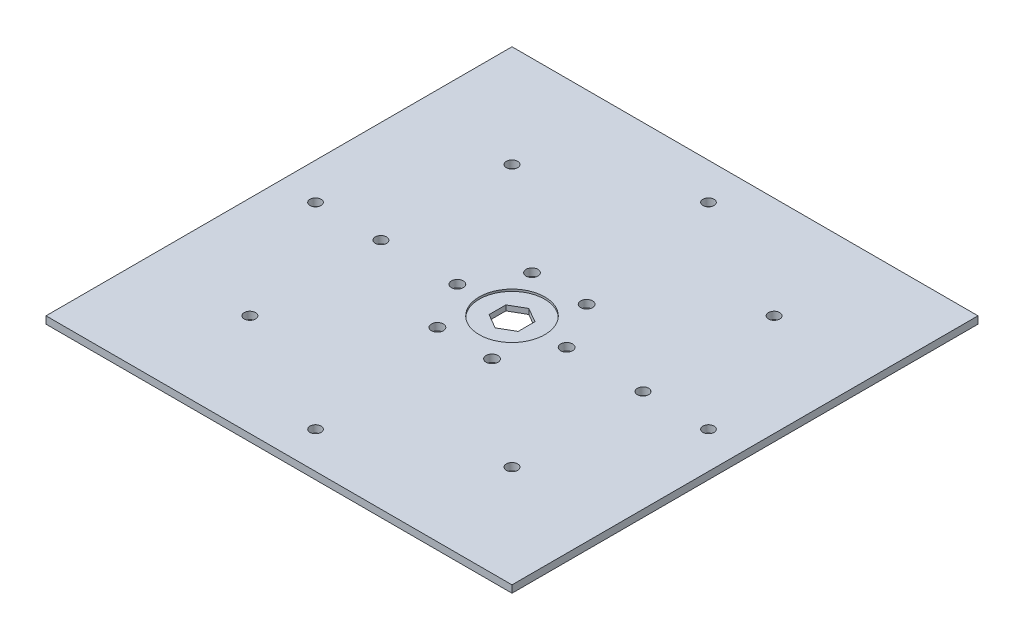
from build123d import *

# Parameters (mm, degrees)
SKETCH1_W           = 203.2
SKETCH1_H           = 203.2
SKETCH1_R           = 2.45745
SKETCH1_R_2         = 2.5908
SKETCH1_R_3         = 2.413
BOSS_EXTRUDE1_DEPTH = 3.175
SKETCH2_R           = 14.2875
CUT_EXTRUDE1_DEPTH  = 0.889


with BuildPart() as part:
    # Sketch1 → Boss-Extrude1 (new body)
    with BuildSketch(Plane(origin=(0, 0, 0), x_dir=(1, 0, 0), z_dir=(0, 1, 0))):
        with Locations((101.6, 101.6)):
            Rectangle(SKETCH1_W, SKETCH1_H)
        with Locations((44.45, 158.75)):
            Circle(SKETCH1_R, mode=Mode.SUBTRACT)
        with Locations((44.45, 101.6)):
            Circle(SKETCH1_R, mode=Mode.SUBTRACT)
        with Locations((44.45, 44.45)):
            Circle(SKETCH1_R, mode=Mode.SUBTRACT)
        with Locations((158.75, 44.45)):
            Circle(SKETCH1_R, mode=Mode.SUBTRACT)
        with Locations((158.75, 101.6)):
            Circle(SKETCH1_R, mode=Mode.SUBTRACT)
        with Locations((158.75, 158.75)):
            Circle(SKETCH1_R, mode=Mode.SUBTRACT)
        with Locations((77.7875, 101.6)):
            Circle(SKETCH1_R_2, mode=Mode.SUBTRACT)
        with Locations((89.69375, 122.222229928)):
            Circle(SKETCH1_R_2, mode=Mode.SUBTRACT)
        with Locations((89.69375, 80.977770072)):
            Circle(SKETCH1_R_2, mode=Mode.SUBTRACT)
        with Locations((113.50625, 122.222229928)):
            Circle(SKETCH1_R_2, mode=Mode.SUBTRACT)
        with Locations((125.4125, 101.6)):
            Circle(SKETCH1_R_2, mode=Mode.SUBTRACT)
        with Locations((113.50625, 80.977770072)):
            Circle(SKETCH1_R_2, mode=Mode.SUBTRACT)
        with Locations((101.6, 187.271643395)):
            Circle(SKETCH1_R_3, mode=Mode.SUBTRACT)
        with Locations((187.271643395, 101.6)):
            Circle(SKETCH1_R_3, mode=Mode.SUBTRACT)
        with Locations((101.6, 15.928356605)):
            Circle(SKETCH1_R_3, mode=Mode.SUBTRACT)
        with Locations((15.928356605, 101.6)):
            Circle(SKETCH1_R_3, mode=Mode.SUBTRACT)
        Polygon((107.95, 105.266174209), (101.6, 108.932348419), (95.25, 105.266174209), (95.25, 97.933825791), (101.6, 94.267651581), (107.95, 97.933825791), align=None, mode=Mode.SUBTRACT)
    extrude(amount=BOSS_EXTRUDE1_DEPTH)

    # Sketch2 → Cut-Extrude1 (cut)
    with BuildSketch(Plane(origin=(0, 3.175, 0), x_dir=(1, 0, 0), z_dir=(0, 1, 0))):
        with Locations((101.6, 101.6)):
            Circle(SKETCH2_R)
    extrude(amount=-CUT_EXTRUDE1_DEPTH, mode=Mode.SUBTRACT)


solid = part.part
